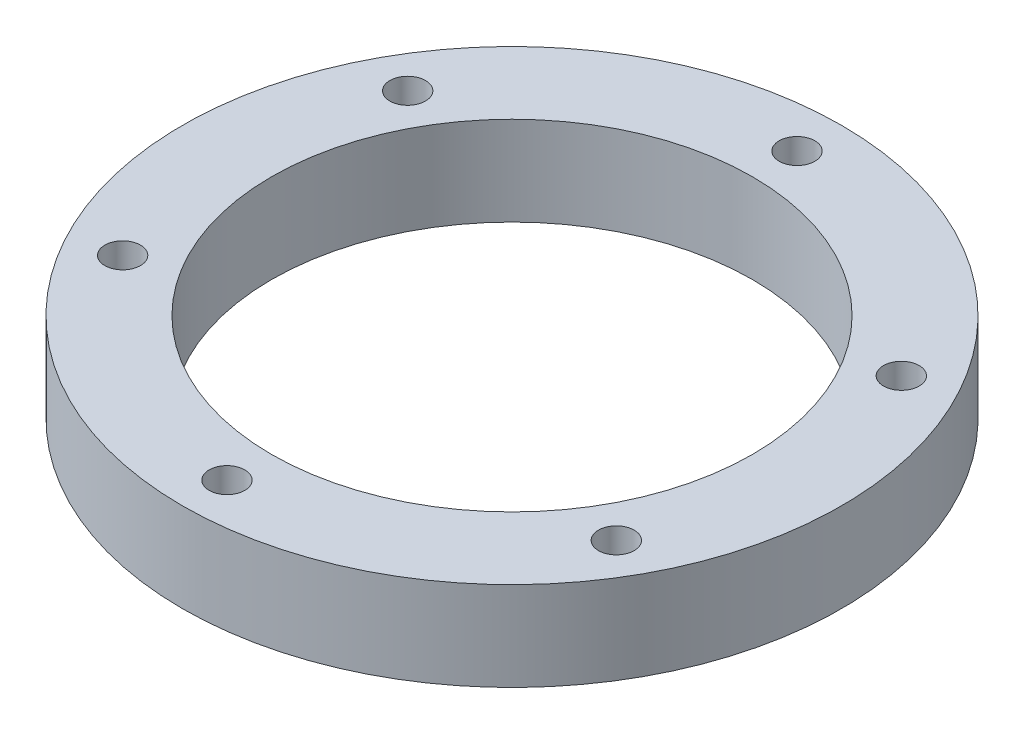
from build123d import *

# Parameters (mm, degrees)
SKETCH1_R           = 45
BOSS_EXTRUDE1_DEPTH = 10
SKETCH2_R           = 45
SKETCH2_R_2         = 37
SKETCH2_R_3         = 27
CUT_EXTRUDE1_DEPTH  = 10
SKETCH3_R           = 2
CUT_EXTRUDE2_DEPTH  = 10


with BuildPart() as part:
    # Sketch1 → Boss-Extrude1 (new body)
    with BuildSketch(Plane(origin=(0, 0, 0), x_dir=(1, 0, 0), z_dir=(0, 1, 0))):
        with Locations(Location((0, 0, 0), (0, 0, 270))):
            Circle(SKETCH1_R)
    extrude(amount=BOSS_EXTRUDE1_DEPTH)

    # Sketch2 → Cut-Extrude1 (cut)
    with BuildSketch(Plane(origin=(0, 10, 0), x_dir=(1, 0, 0), z_dir=(0, 1, 0))):
        Circle(SKETCH2_R)
        with Locations(Location((0, 0, 0), (0, 0, 270))):
            Circle(SKETCH2_R_2, mode=Mode.SUBTRACT)
        with Locations(Location((0, 0, 0), (0, 0, 270))):
            Circle(SKETCH2_R_3)
    extrude(amount=-CUT_EXTRUDE1_DEPTH, mode=Mode.SUBTRACT)

    # Sketch3 → Cut-Extrude2 (cut)
    with BuildSketch(Plane(origin=(0, 10, 0), x_dir=(1, 0, 0), z_dir=(0, 1, 0))):
        with Locations(Location((0, 32, 0), (0, 0, 270))):
            Circle(SKETCH3_R)
        with Locations(Location((27.712812921, 16, 0), (0, 0, 270))):
            Circle(SKETCH3_R)
        with Locations(Location((27.712812921, -16, 0), (0, 0, 270))):
            Circle(SKETCH3_R)
        with Locations(Location((0, -32, 0), (0, 0, 270))):
            Circle(SKETCH3_R)
        with Locations(Location((-27.712812921, -16, 0), (0, 0, 270))):
            Circle(SKETCH3_R)
        with Locations(Location((-27.712812921, 16, 0), (0, 0, 270))):
            Circle(SKETCH3_R)
    extrude(amount=-CUT_EXTRUDE2_DEPTH, mode=Mode.SUBTRACT)


solid = part.part
